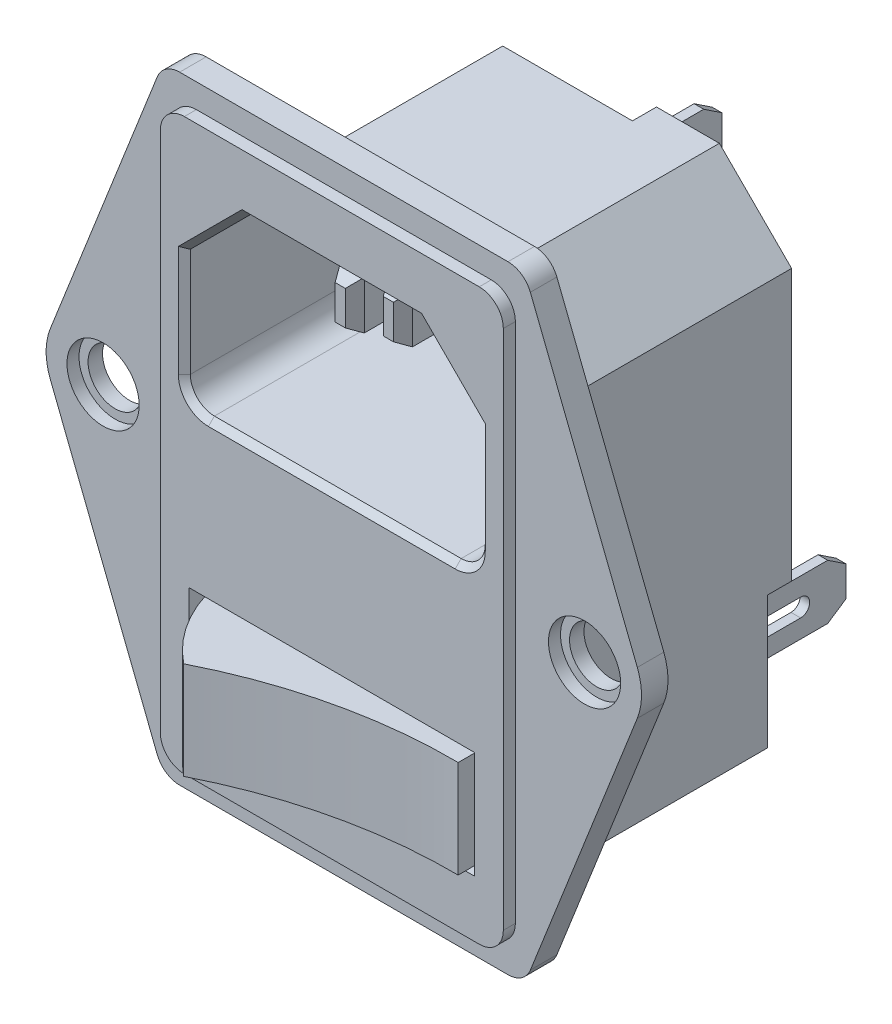
from build123d import *

# Parameters (mm, degrees)
EXTRUDE_1_DEPTH         = 2.2
EXTRUDE_START           = -2.2
SKETCH_2_W              = 28.5
SKETCH_2_H              = 47.3
EXTRUDE_2_DEPTH         = 3.2
SKETCH_3_R              = 2.25
CUT_EXTRUDE_1_DEPTH     = 3.2
SKETCH_4_R              = 3
CUT_EXTRUDE_2_DEPTH     = 1
FILLET_1_R              = 2
FILLET_2_R              = 5
EXTRUDE_3_DEPTH         = 21
SKETCH_6_W              = 23.7
SKETCH_6_H              = 8.9
CUT_EXTRUDE_3_DEPTH     = 3
SKETCH_8_W              = 5.4
SKETCH_8_H              = 11
CUT_EXTRUDE_4_DEPTH     = 2
SKETCH_9_W              = 3
SKETCH_9_H              = 10.5
SKETCH_9_H_2            = 8
SKETCH_9_W_2            = 5.5
SKETCH_9_H_3            = 5.5
EXTRUDE_4_DEPTH         = 2.1
SKETCH_10_W             = 0.8
SKETCH_10_H             = 4.55
EXTRUDE_5_DEPTH         = 9.8
CUT_EXTRUDE_5_DEPTH     = 0.8
CUT_EXTRUDE_6_DEPTH     = 0.8
CUT_EXTRUDE_7_DEPTH     = 0.8
CHAMFER_1_SIZE          = 1.5
CHAMFER_1_SIZE2         = 1
CHAMFER_1_PART_2_SIZE   = 1.5
CHAMFER_1_PART_2_SIZE2  = 1
CHAMFER_1_PART_3_SIZE   = 1.5
CHAMFER_1_PART_3_SIZE2  = 1
CHAMFER_1_PART_4_SIZE   = 1.5
CHAMFER_1_PART_4_SIZE2  = 1
CHAMFER_1_PART_5_SIZE   = 1.5
CHAMFER_1_PART_5_SIZE2  = 1
CHAMFER_1_PART_6_SIZE   = 1.5
CHAMFER_1_PART_6_SIZE2  = 1
CUT_EXTRUDE_8_DEPTH     = 19.7
CHAMFER_2_SIZE          = 0.5
SKETCH_15_W             = 2
SKETCH_15_H             = 4
EXTRUDE_6_DEPTH         = 12
SKETCH_16_W             = 2
SKETCH_16_H             = 4
EXTRUDE_7_DEPTH         = 3
CHAMFER_3_SIZE          = 1
CHAMFER_3_SIZE2         = 0.577350269
CHAMFER_3_PART_2_SIZE   = 1
CHAMFER_3_PART_2_SIZE2  = 0.577350269
CHAMFER_3_PART_3_SIZE   = 1
CHAMFER_3_PART_3_SIZE2  = 0.577350269
CHAMFER_3_PART_4_SIZE   = 1
CHAMFER_3_PART_4_SIZE2  = 0.577350269
CHAMFER_3_PART_5_SIZE   = 1
CHAMFER_3_PART_5_SIZE2  = 0.577350269
CHAMFER_3_PART_6_SIZE   = 1
CHAMFER_3_PART_6_SIZE2  = 0.577350269
CHAMFER_3_PART_7_SIZE   = 1
CHAMFER_3_PART_7_SIZE2  = 0.577350269
CHAMFER_3_PART_8_SIZE   = 1
CHAMFER_3_PART_8_SIZE2  = 0.577350269
CHAMFER_3_PART_9_SIZE   = 1
CHAMFER_3_PART_9_SIZE2  = 0.577350269
CHAMFER_3_PART_10_SIZE  = 1
CHAMFER_3_PART_10_SIZE2 = 0.577350269
CHAMFER_3_PART_11_SIZE  = 1
CHAMFER_3_PART_11_SIZE2 = 0.577350269
CHAMFER_3_PART_12_SIZE  = 1
CHAMFER_3_PART_12_SIZE2 = 0.577350269
EXTRUDE_8_DEPTH         = 33.35
SKETCH_18_W             = 23
SKETCH_18_H             = 8.1
EXTRUDE_9_DEPTH         = 8.3
CUT_EXTRUDE_9_DEPTH     = 8.1


with BuildPart() as part:
    # Эскиз1 → Бобышка-Вытянуть1 (new body)
    with BuildSketch(Plane.XY):
        Polygon((-15, 25.65), (-25.1038037, 0), (-15, -25.65), (15, -25.65), (25.1038037, 0), (15, 25.65), align=None)
    extrude(amount=EXTRUDE_1_DEPTH)

    # Эскиз2 → Бобышка-Вытянуть2 (add)
    with BuildSketch(Plane.XY.offset(2.2).offset(EXTRUDE_START)):
        Rectangle(SKETCH_2_W, SKETCH_2_H)
    extrude(amount=EXTRUDE_2_DEPTH)

    # Эскиз3 → Вырез-Вытянуть1 (cut)
    with BuildSketch(Plane.XY.offset(2.2)):
        with Locations((-20, 0)):
            Circle(SKETCH_3_R)
        with Locations((20, 0)):
            Circle(SKETCH_3_R)
    extrude(amount=-CUT_EXTRUDE_1_DEPTH, mode=Mode.SUBTRACT)

    # Эскиз4 → Вырез-Вытянуть2 (cut)
    with BuildSketch(Plane.XY.offset(2.2)):
        with Locations((-20, 0)):
            Circle(SKETCH_4_R)
        with Locations((20, 0)):
            Circle(SKETCH_4_R)
    extrude(amount=-CUT_EXTRUDE_2_DEPTH, mode=Mode.SUBTRACT)

    # Скругление1
    fillet_1_edges = [part.edges().sort_by_distance(p)[0] for p in [
        (15, -25.65, 1.1),
        (-15, -25.65, 1.1),
        (-15, 25.65, 1.1),
        (15, 25.65, 1.1),
        (14.25, -23.65, 2.7),
        (14.25, 23.65, 2.7),
        (-14.25, 23.65, 2.7),
        (-14.25, -23.65, 2.7),
    ]]
    fillet(fillet_1_edges, radius=FILLET_1_R)

    # Скругление2
    fillet_2_edges = [part.edges().sort_by_distance(p)[0] for p in [
        (25.1038037, 0, 1.1),
        (-25.1038037, 0, 1.1),
    ]]
    fillet(fillet_2_edges, radius=FILLET_2_R)

    # Эскиз7 → Бобышка-Вытянуть3 (add)
    with BuildSketch(Plane(origin=(0, 0, 0), x_dir=(-1, 0, 0), z_dir=(0, 0, -1))):
        Polygon((-14, 13.75), (-8, 19.75), (8, 19.75), (14, 13.75), (14, -19.75), (-14, -19.75), align=None)
    extrude(amount=EXTRUDE_3_DEPTH)

    # Эскиз6 → Вырез-Вытянуть3 (cut)
    with BuildSketch(Plane.XY.offset(3.2)):
        with Locations((0, -14.5)):
            Rectangle(SKETCH_6_W, SKETCH_6_H)
    extrude(amount=-CUT_EXTRUDE_3_DEPTH, mode=Mode.SUBTRACT)

    # Эскиз8 → Вырез-Вытянуть4 (cut)
    with BuildSketch(Plane(origin=(0, 0, -21), x_dir=(-1, 0, 0), z_dir=(0, 0, -1))):
        with Locations((-11.3, -14.25)):
            Rectangle(SKETCH_8_W, SKETCH_8_H)
        Polygon((-2.775, 8.35), (2.775, 8.35), (2.775, 12.55), (14, 12.55), (14, 19.75), (2.775, 19.75), (-2.775, 19.75), align=None)
        with Locations((11.3, -14.25)):
            Rectangle(SKETCH_8_W, SKETCH_8_H)
    extrude(amount=-CUT_EXTRUDE_4_DEPTH, mode=Mode.SUBTRACT)

    # Эскиз9 → Бобышка-Вытянуть4 (add)
    with BuildSketch(Plane(origin=(0, 0, -21), x_dir=(-1, 0, 0), z_dir=(0, 0, -1))):
        with Locations((0, -14.5)):
            Rectangle(SKETCH_9_W, SKETCH_9_H)
        with Locations((-5, -3.75)):
            Rectangle(SKETCH_9_W, SKETCH_9_H_2)
        with Locations((-7.05, 8.8)):
            Rectangle(SKETCH_9_W_2, SKETCH_9_H_3)
        with Locations((7.05, 8.8)):
            Rectangle(SKETCH_9_W_2, SKETCH_9_H_3)
        with Locations((5, -3.75)):
            Rectangle(SKETCH_9_W, SKETCH_9_H_2)
    extrude(amount=EXTRUDE_4_DEPTH)

    # Эскиз10 → Бобышка-Вытянуть5 (add)
    with BuildSketch(Plane(origin=(0, 0, -19), x_dir=(-1, 0, 0), z_dir=(0, 0, -1))):
        with Locations((0, 12.975)):
            Rectangle(SKETCH_10_W, SKETCH_10_H)
        with Locations((-10.3, -14.325)):
            Rectangle(SKETCH_10_W, SKETCH_10_H)
        with Locations((10.3, -14.325)):
            Rectangle(SKETCH_10_W, SKETCH_10_H)
    extrude(amount=EXTRUDE_5_DEPTH)

    # Эскиз11 → Вырез-Вытянуть5 (cut)
    with BuildSketch(Plane.ZY.offset(10.7)):
        with BuildLine():
            Line((-25.05, -13.575), (-21.55, -13.575))
            ThreePointArc((-21.55, -13.575), (-20.8, -14.325), (-21.55, -15.075))
            Line((-21.55, -15.075), (-25.05, -15.075))
            ThreePointArc((-25.05, -15.075), (-25.8, -14.325), (-25.05, -13.575))
        make_face()
    extrude(amount=-CUT_EXTRUDE_5_DEPTH, mode=Mode.SUBTRACT)

    # Эскиз12 → Вырез-Вытянуть6 (cut)
    with BuildSketch(Plane(origin=(10.7, 0, 0), x_dir=(0, 0, -1), z_dir=(1, 0, 0))):
        with BuildLine():
            Line((25.05, -13.575), (21.55, -13.575))
            ThreePointArc((21.55, -13.575), (20.8, -14.325), (21.55, -15.075))
            Line((21.55, -15.075), (25.05, -15.075))
            ThreePointArc((25.05, -15.075), (25.8, -14.325), (25.05, -13.575))
        make_face()
    extrude(amount=-CUT_EXTRUDE_6_DEPTH, mode=Mode.SUBTRACT)

    # Эскиз13 → Вырез-Вытянуть7 (cut)
    with BuildSketch(Plane.ZY.offset(0.4)):
        with BuildLine():
            Line((-21.55, 12.225), (-25.05, 12.225))
            ThreePointArc((-25.05, 12.225), (-25.8, 12.975), (-25.05, 13.725))
            Line((-25.05, 13.725), (-21.55, 13.725))
            ThreePointArc((-21.55, 13.725), (-20.8, 12.975), (-21.55, 12.225))
        make_face()
    extrude(amount=-CUT_EXTRUDE_7_DEPTH, mode=Mode.SUBTRACT)

    # Фаска1
    chamfer_1_edges = [part.edges().sort_by_distance(p)[0] for p in [
        (0, 15.25, -28.8),
    ]]
    chamfer_1_side = [part.faces().sort_by_distance(p)[0] for p in [
        (0, 15.25, -23.9),
    ]]
    chamfer(chamfer_1_edges, length=CHAMFER_1_SIZE, length2=CHAMFER_1_SIZE2, reference=chamfer_1_side[0])

    # Фаска1 part 2
    chamfer_1_part_2_edges = [part.edges().sort_by_distance(p)[0] for p in [
        (0, 10.7, -28.8),
    ]]
    chamfer_1_part_2_side = [part.faces().sort_by_distance(p)[0] for p in [
        (0, 10.7, -23.9),
    ]]
    chamfer(chamfer_1_part_2_edges, length=CHAMFER_1_PART_2_SIZE, length2=CHAMFER_1_PART_2_SIZE2, reference=chamfer_1_part_2_side[0])

    # Фаска1 part 3
    chamfer_1_part_3_edges = [part.edges().sort_by_distance(p)[0] for p in [
        (10.3, -12.05, -28.8),
    ]]
    chamfer_1_part_3_side = [part.faces().sort_by_distance(p)[0] for p in [
        (10.3, -12.05, -23.9),
    ]]
    chamfer(chamfer_1_part_3_edges, length=CHAMFER_1_PART_3_SIZE, length2=CHAMFER_1_PART_3_SIZE2, reference=chamfer_1_part_3_side[0])

    # Фаска1 part 4
    chamfer_1_part_4_edges = [part.edges().sort_by_distance(p)[0] for p in [
        (10.3, -16.6, -28.8),
    ]]
    chamfer_1_part_4_side = [part.faces().sort_by_distance(p)[0] for p in [
        (10.3, -16.6, -23.9),
    ]]
    chamfer(chamfer_1_part_4_edges, length=CHAMFER_1_PART_4_SIZE, length2=CHAMFER_1_PART_4_SIZE2, reference=chamfer_1_part_4_side[0])

    # Фаска1 part 5
    chamfer_1_part_5_edges = [part.edges().sort_by_distance(p)[0] for p in [
        (-10.3, -12.05, -28.8),
    ]]
    chamfer_1_part_5_side = [part.faces().sort_by_distance(p)[0] for p in [
        (-10.3, -12.05, -23.9),
    ]]
    chamfer(chamfer_1_part_5_edges, length=CHAMFER_1_PART_5_SIZE, length2=CHAMFER_1_PART_5_SIZE2, reference=chamfer_1_part_5_side[0])

    # Фаска1 part 6
    chamfer_1_part_6_edges = [part.edges().sort_by_distance(p)[0] for p in [
        (-10.3, -16.6, -28.8),
    ]]
    chamfer_1_part_6_side = [part.faces().sort_by_distance(p)[0] for p in [
        (-10.3, -16.6, -23.9),
    ]]
    chamfer(chamfer_1_part_6_edges, length=CHAMFER_1_PART_6_SIZE, length2=CHAMFER_1_PART_6_SIZE2, reference=chamfer_1_part_6_side[0])

    # Эскиз14 → Вырез-Вытянуть8 (cut)
    with BuildSketch(Plane.XY.offset(3.2)):
        with BuildLine():
            Line((-10.25, 2.85), (10.25, 2.85))
            ThreePointArc((10.25, 2.85), (11.664213562, 3.435786438), (12.25, 4.85))
            Line((12.25, 4.85), (12.25, 13.85))
            Line((12.25, 13.85), (7.25, 18.85))
            Line((7.25, 18.85), (-7.25, 18.85))
            Line((-7.25, 18.85), (-12.25, 13.85))
            Line((-12.25, 13.85), (-12.25, 4.85))
            ThreePointArc((-12.25, 4.85), (-11.664213562, 3.435786438), (-10.25, 2.85))
        make_face()
    extrude(amount=-CUT_EXTRUDE_8_DEPTH, mode=Mode.SUBTRACT)

    # Фаска2
    chamfer_2_edges = [part.edges().sort_by_distance(p)[0] for p in [
        (11.664213562, 3.435786438, 3.2),
        (12.25, 9.35, 3.2),
        (9.75, 16.35, 3.2),
        (0, 18.85, 3.2),
        (-9.75, 16.35, 3.2),
        (-12.25, 9.35, 3.2),
        (-11.664213562, 3.435786438, 3.2),
        (0, 2.85, 3.2),
    ]]
    chamfer(chamfer_2_edges, length=CHAMFER_2_SIZE)

    # Эскиз15 → Бобышка-Вытянуть6 (add)
    with BuildSketch(Plane.XY.offset(-16.5)):
        with Locations((0, 12.85)):
            Rectangle(SKETCH_15_W, SKETCH_15_H)
        with Locations((-7, 8.85)):
            Rectangle(SKETCH_15_W, SKETCH_15_H)
        with Locations((7, 8.85)):
            Rectangle(SKETCH_15_W, SKETCH_15_H)
    extrude(amount=EXTRUDE_6_DEPTH)

    # Эскиз16 → Бобышка-Вытянуть7 (add)
    with BuildSketch(Plane.XY.offset(-4.5)):
        with Locations((0, 12.85)):
            Rectangle(SKETCH_16_W, SKETCH_16_H)
    extrude(amount=EXTRUDE_7_DEPTH)

    # Фаска3
    chamfer_3_edges = [part.edges().sort_by_distance(p)[0] for p in [
        (-6, 8.85, -4.5),
    ]]
    chamfer_3_side = [part.faces().sort_by_distance(p)[0] for p in [
        (-6, 8.85, -10.5),
    ]]
    chamfer(chamfer_3_edges, length=CHAMFER_3_SIZE, length2=CHAMFER_3_SIZE2, reference=chamfer_3_side[0])

    # Фаска3 part 2
    chamfer_3_part_2_edges = [part.edges().sort_by_distance(p)[0] for p in [
        (-7, 10.85, -4.5),
    ]]
    chamfer_3_part_2_side = [part.faces().sort_by_distance(p)[0] for p in [
        (-7, 10.85, -10.5),
    ]]
    chamfer(chamfer_3_part_2_edges, length=CHAMFER_3_PART_2_SIZE, length2=CHAMFER_3_PART_2_SIZE2, reference=chamfer_3_part_2_side[0])

    # Фаска3 part 3
    chamfer_3_part_3_edges = [part.edges().sort_by_distance(p)[0] for p in [
        (-8, 8.85, -4.5),
    ]]
    chamfer_3_part_3_side = [part.faces().sort_by_distance(p)[0] for p in [
        (-8, 8.85, -10.5),
    ]]
    chamfer(chamfer_3_part_3_edges, length=CHAMFER_3_PART_3_SIZE, length2=CHAMFER_3_PART_3_SIZE2, reference=chamfer_3_part_3_side[0])

    # Фаска3 part 4
    chamfer_3_part_4_edges = [part.edges().sort_by_distance(p)[0] for p in [
        (-7, 6.85, -4.5),
    ]]
    chamfer_3_part_4_side = [part.faces().sort_by_distance(p)[0] for p in [
        (-7, 6.85, -10.5),
    ]]
    chamfer(chamfer_3_part_4_edges, length=CHAMFER_3_PART_4_SIZE, length2=CHAMFER_3_PART_4_SIZE2, reference=chamfer_3_part_4_side[0])

    # Фаска3 part 5
    chamfer_3_part_5_edges = [part.edges().sort_by_distance(p)[0] for p in [
        (8, 8.85, -4.5),
    ]]
    chamfer_3_part_5_side = [part.faces().sort_by_distance(p)[0] for p in [
        (8, 8.85, -10.5),
    ]]
    chamfer(chamfer_3_part_5_edges, length=CHAMFER_3_PART_5_SIZE, length2=CHAMFER_3_PART_5_SIZE2, reference=chamfer_3_part_5_side[0])

    # Фаска3 part 6
    chamfer_3_part_6_edges = [part.edges().sort_by_distance(p)[0] for p in [
        (7, 10.85, -4.5),
    ]]
    chamfer_3_part_6_side = [part.faces().sort_by_distance(p)[0] for p in [
        (7, 10.85, -10.5),
    ]]
    chamfer(chamfer_3_part_6_edges, length=CHAMFER_3_PART_6_SIZE, length2=CHAMFER_3_PART_6_SIZE2, reference=chamfer_3_part_6_side[0])

    # Фаска3 part 7
    chamfer_3_part_7_edges = [part.edges().sort_by_distance(p)[0] for p in [
        (6, 8.85, -4.5),
    ]]
    chamfer_3_part_7_side = [part.faces().sort_by_distance(p)[0] for p in [
        (6, 8.85, -10.5),
    ]]
    chamfer(chamfer_3_part_7_edges, length=CHAMFER_3_PART_7_SIZE, length2=CHAMFER_3_PART_7_SIZE2, reference=chamfer_3_part_7_side[0])

    # Фаска3 part 8
    chamfer_3_part_8_edges = [part.edges().sort_by_distance(p)[0] for p in [
        (7, 6.85, -4.5),
    ]]
    chamfer_3_part_8_side = [part.faces().sort_by_distance(p)[0] for p in [
        (7, 6.85, -10.5),
    ]]
    chamfer(chamfer_3_part_8_edges, length=CHAMFER_3_PART_8_SIZE, length2=CHAMFER_3_PART_8_SIZE2, reference=chamfer_3_part_8_side[0])

    # Фаска3 part 9
    chamfer_3_part_9_edges = [part.edges().sort_by_distance(p)[0] for p in [
        (0, 10.85, -1.5),
    ]]
    chamfer_3_part_9_side = [part.faces().sort_by_distance(p)[0] for p in [
        (0, 10.85, -9),
    ]]
    chamfer(chamfer_3_part_9_edges, length=CHAMFER_3_PART_9_SIZE, length2=CHAMFER_3_PART_9_SIZE2, reference=chamfer_3_part_9_side[0])

    # Фаска3 part 10
    chamfer_3_part_10_edges = [part.edges().sort_by_distance(p)[0] for p in [
        (1, 12.85, -1.5),
    ]]
    chamfer_3_part_10_side = [part.faces().sort_by_distance(p)[0] for p in [
        (1, 12.85, -9),
    ]]
    chamfer(chamfer_3_part_10_edges, length=CHAMFER_3_PART_10_SIZE, length2=CHAMFER_3_PART_10_SIZE2, reference=chamfer_3_part_10_side[0])

    # Фаска3 part 11
    chamfer_3_part_11_edges = [part.edges().sort_by_distance(p)[0] for p in [
        (0, 14.85, -1.5),
    ]]
    chamfer_3_part_11_side = [part.faces().sort_by_distance(p)[0] for p in [
        (0, 14.85, -9),
    ]]
    chamfer(chamfer_3_part_11_edges, length=CHAMFER_3_PART_11_SIZE, length2=CHAMFER_3_PART_11_SIZE2, reference=chamfer_3_part_11_side[0])

    # Фаска3 part 12
    chamfer_3_part_12_edges = [part.edges().sort_by_distance(p)[0] for p in [
        (-1, 12.85, -1.5),
    ]]
    chamfer_3_part_12_side = [part.faces().sort_by_distance(p)[0] for p in [
        (-1, 12.85, -9),
    ]]
    chamfer(chamfer_3_part_12_edges, length=CHAMFER_3_PART_12_SIZE, length2=CHAMFER_3_PART_12_SIZE2, reference=chamfer_3_part_12_side[0])

    # Эскиз17 → Бобышка-Вытянуть8 (add)
    with BuildSketch(Plane.XZ.offset(19.75)):
        Polygon((-14.8, 0), (-14.8, -2), (-14, -3), (-14, 0), align=None)
        Polygon((14, -3), (14, 0), (14.8, 0), (14.8, -2), align=None)
    extrude(amount=-EXTRUDE_8_DEPTH)


with BuildPart() as body_2:
    # Эскиз18 → Бобышка-Вытянуть9 (new body)
    with BuildSketch(Plane.XY.offset(0.2)):
        with Locations((0, -14.5)):
            Rectangle(SKETCH_18_W, SKETCH_18_H)
    extrude(amount=EXTRUDE_9_DEPTH)

    # Эскиз19 → Вырез-Вытянуть9 (cut)
    with BuildSketch(Plane.XZ.offset(18.55)):
        with BuildLine():
            Line((-11.5, 0.2), (-11.5, 10.2))
            Line((-11.5, 10.2), (11.5, 10.2))
            Line((11.5, 10.2), (11.5, 4.2))
            ThreePointArc((11.5, 4.2), (1.991077966, 5.23603311), (-7, 8.5))
            ThreePointArc((-7, 8.5), (-10.100578182, 4.811156846), (-11.5, 0.2))
        make_face()
    extrude(amount=-CUT_EXTRUDE_9_DEPTH, mode=Mode.SUBTRACT)


solid = Compound([part.part, body_2.part])
